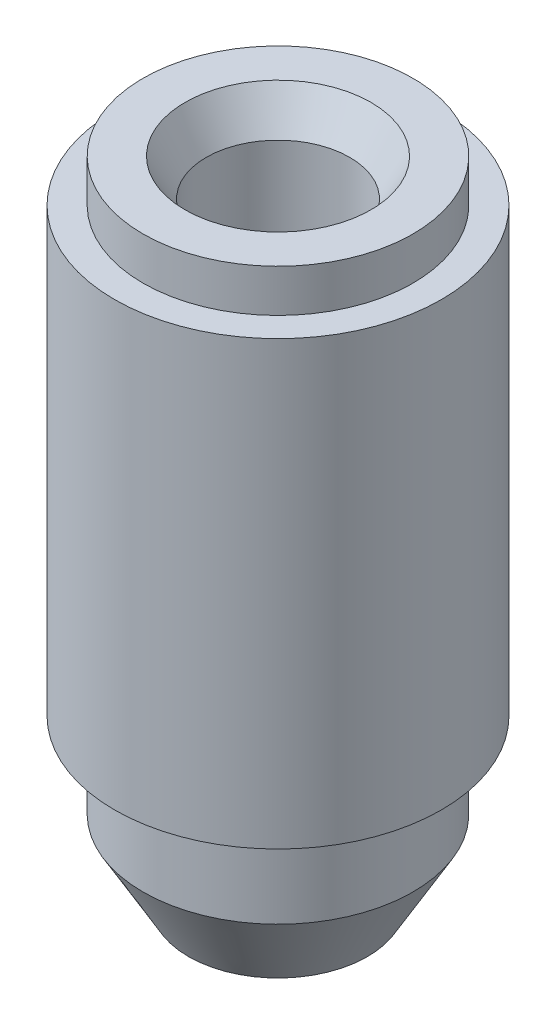
from build123d import *

# Parameters (mm, degrees)
CHAMFER1_SIZE  = 1.5
CHAMFER1_SIZE2 = 2.598076211


with BuildPart() as part:
    # Sketch1 → Revolve1 (revolve)
    with BuildSketch(Plane.XY):
        Polygon((5.05, -18.56), (5.05, 18.56), (9.5, 18.56), (9.5, 15.56), (11.5, 15.56), (11.5, -15.56), (9.5, -15.56), (9.5, -18.56), (9.5, -21.56), (6.3, -27.102562584), (5.05, -27.102562584), align=None)
    revolve(axis=Axis((0, 19.533170402, 0), (0, -1, 0)))

    # Chamfer1
    chamfer1_edges = [part.edges().sort_by_distance(p)[0] for p in [
        (-5.05, 18.56, 0),
    ]]
    chamfer1_side = [part.faces().sort_by_distance(p)[0] for p in [
        (-5.318700577, 18.56, 0),
    ]]
    chamfer(chamfer1_edges, length=CHAMFER1_SIZE, length2=CHAMFER1_SIZE2, reference=chamfer1_side[0])


solid = part.part
